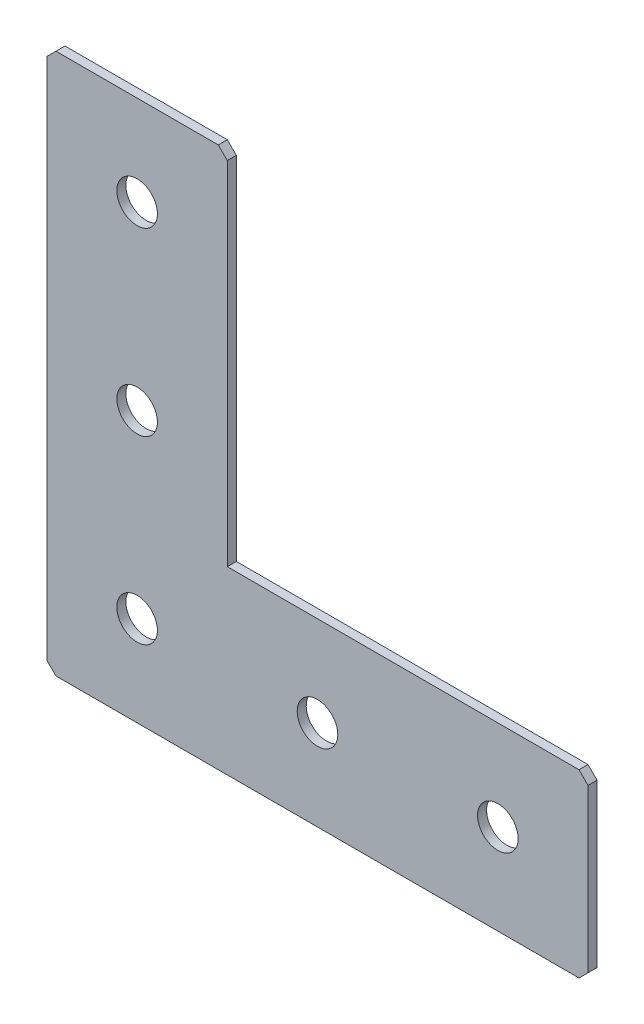
from build123d import *

# Parameters (mm, degrees)
EXTRUDE_1_DEPTH   = 2
HOLE_WIZARD_M81_D = 9
CHAMFER_1_SIZE    = 2


with BuildPart() as part:
    # Эскиз1 → Бобышка-Вытянуть1 (new body)
    with BuildSketch(Plane(origin=(0, 0, 0), x_dir=(1, 0, 0), z_dir=(0, 0, -1))):
        Polygon((0, 0), (0, 120), (120, 120), (120, 80), (40, 80), (40, 0), align=None)
    extrude(amount=EXTRUDE_1_DEPTH)

    # Отверстие с зазором M81 (through all)
    with Locations(Plane(origin=(0, 0, -2), x_dir=(1, 0, 0), z_dir=(0, 0, -1))):
        with Locations((60, 100), (20, 100), (20, 60), (20, 20), (100, 100)):
            Hole(HOLE_WIZARD_M81_D / 2)

    # Фаска1
    chamfer_1_edges = [part.edges().sort_by_distance(p)[0] for p in [
        (0, 0, -1),
        (0, -120, -1),
        (120, -120, -1),
        (120, -80, -1),
        (40, 0, -1),
    ]]
    chamfer(chamfer_1_edges, length=CHAMFER_1_SIZE)


solid = part.part
